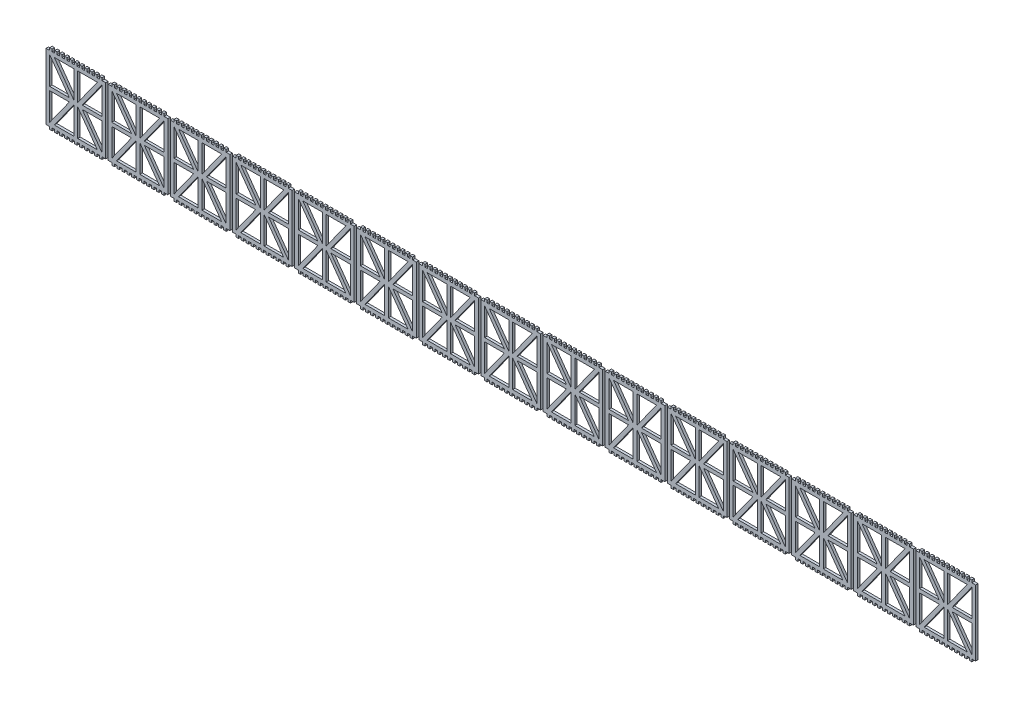
from build123d import *

# Parameters (mm, degrees)
BOSS_EXTRUDE1_DEPTH    = 4
BOSS_EXTRUDE1_2_DEPTH  = 4
BOSS_EXTRUDE1_3_DEPTH  = 4
BOSS_EXTRUDE1_4_DEPTH  = 4
BOSS_EXTRUDE1_5_DEPTH  = 4
BOSS_EXTRUDE1_6_DEPTH  = 4
BOSS_EXTRUDE1_7_DEPTH  = 4
BOSS_EXTRUDE1_8_DEPTH  = 4
BOSS_EXTRUDE1_9_DEPTH  = 4
BOSS_EXTRUDE1_10_DEPTH = 4
BOSS_EXTRUDE1_11_DEPTH = 4
BOSS_EXTRUDE1_12_DEPTH = 4
BOSS_EXTRUDE1_13_DEPTH = 4
BOSS_EXTRUDE1_14_DEPTH = 4
BOSS_EXTRUDE1_15_DEPTH = 4
CUT_EXTRUDE5_DEPTH     = 4


with BuildPart() as part:
    # Sketch1 → Boss-Extrude1 (new body)
    with BuildSketch(Plane.XY):
        Polygon((-42.553329981, 24.0700813), (-36.553329981, 24.0700813), (-36.553329981, 28.0700813), (-32.553329981, 28.0700813), (-32.553329981, 24.0700813), (-28.553329981, 24.0700813), (-28.553329981, 28.0700813), (-24.553329981, 28.0700813), (-24.553329981, 24.0700813), (-20.553329981, 24.0700813), (-20.553329981, 28.0700813), (-16.553329981, 28.0700813), (-16.553329981, 24.0700813), (-12.553329981, 24.0700813), (-12.553329981, 28.0700813), (-8.553329981, 28.0700813), (-8.553329981, 24.0700813), (-4.553329981, 24.0700813), (-4.553329981, 28.0700813), (-0.553329981, 28.0700813), (-0.553329981, 24.0700813), (3.446670019, 24.0700813), (3.446670019, 28.0700813), (7.446670019, 28.0700813), (7.446670019, 24.0700813), (11.446670019, 24.0700813), (11.446670019, 28.0700813), (15.446670019, 28.0700813), (15.446670019, 24.0700813), (19.446670019, 24.0700813), (19.446670019, 28.0700813), (23.446670019, 28.0700813), (23.446670019, 24.0700813), (27.446670019, 24.0700813), (27.446670019, 28.0700813), (31.446670019, 28.0700813), (31.446670019, 24.0700813), (35.446670019, 24.0700813), (35.446670019, 28.0700813), (39.446670019, 28.0700813), (39.446670019, 24.0700813), (43.446670019, 24.0700813), (43.446670019, 28.0700813), (47.446670019, 28.0700813), (47.446670019, 24.0700813), (51.446670019, 24.0700813), (53.446670019, 24.0700813), (53.446670019, -82.0699187), (51.446670019, -82.0699187), (47.446670019, -82.0699187), (47.446670019, -86.0699187), (43.446670019, -86.0699187), (43.446670019, -82.0699187), (39.446670019, -82.0699187), (39.446670019, -86.0699187), (35.446670019, -86.0699187), (35.446670019, -82.0699187), (31.446670019, -82.0699187), (31.446670019, -86.0699187), (27.446670019, -86.0699187), (27.446670019, -82.0699187), (23.446670019, -82.0699187), (23.446670019, -86.0699187), (19.446670019, -86.0699187), (19.446670019, -82.0699187), (15.446670019, -82.0699187), (15.446670019, -86.0699187), (11.446670019, -86.0699187), (11.446670019, -82.0699187), (7.446670019, -82.0699187), (7.446670019, -86.0699187), (3.446670019, -86.0699187), (3.446670019, -82.0699187), (-0.553329981, -82.0699187), (-0.553329981, -86.0699187), (-4.553329981, -86.0699187), (-4.553329981, -82.0699187), (-8.553329981, -82.0699187), (-8.553329981, -86.0699187), (-12.553329981, -86.0699187), (-12.553329981, -82.0699187), (-16.553329981, -82.0699187), (-16.553329981, -86.0699187), (-20.553329981, -86.0699187), (-20.553329981, -82.0699187), (-24.553329981, -82.0699187), (-24.553329981, -86.0699187), (-28.553329981, -86.0699187), (-28.553329981, -82.0699187), (-32.553329981, -82.0699187), (-32.553329981, -86.0699187), (-36.553329981, -86.0699187), (-36.553329981, -82.0699187), (-42.553329981, -82.0699187), align=None)
    extrude(amount=BOSS_EXTRUDE1_DEPTH)


with BuildPart() as body_2:
    # Sketch1 → Boss-Extrude1 2 (new body)
    with BuildSketch(Plane.XY):
        Polygon((57.446670019, 24.0700813), (63.446670019, 24.0700813), (63.446670019, 28.0700813), (67.446670019, 28.0700813), (67.446670019, 24.0700813), (71.446670019, 24.0700813), (71.446670019, 28.0700813), (75.446670019, 28.0700813), (75.446670019, 24.0700813), (79.446670019, 24.0700813), (79.446670019, 28.0700813), (83.446670019, 28.0700813), (83.446670019, 24.0700813), (87.446670019, 24.0700813), (87.446670019, 28.0700813), (91.446670019, 28.0700813), (91.446670019, 24.0700813), (95.446670019, 24.0700813), (95.446670019, 28.0700813), (99.446670019, 28.0700813), (99.446670019, 24.0700813), (103.446670019, 24.0700813), (103.446670019, 28.0700813), (107.446670019, 28.0700813), (107.446670019, 24.0700813), (111.446670019, 24.0700813), (111.446670019, 28.0700813), (115.446670019, 28.0700813), (115.446670019, 24.0700813), (119.446670019, 24.0700813), (119.446670019, 28.0700813), (123.446670019, 28.0700813), (123.446670019, 24.0700813), (127.446670019, 24.0700813), (127.446670019, 28.0700813), (131.446670019, 28.0700813), (131.446670019, 24.0700813), (135.446670019, 24.0700813), (135.446670019, 28.0700813), (139.446670019, 28.0700813), (139.446670019, 24.0700813), (143.446670019, 24.0700813), (143.446670019, 28.0700813), (147.446670019, 28.0700813), (147.446670019, 24.0700813), (151.446670019, 24.0700813), (153.446670019, 24.0700813), (153.446670019, -82.0699187), (151.446670019, -82.0699187), (147.446670019, -82.0699187), (147.446670019, -86.0699187), (143.446670019, -86.0699187), (143.446670019, -82.0699187), (139.446670019, -82.0699187), (139.446670019, -86.0699187), (135.446670019, -86.0699187), (135.446670019, -82.0699187), (131.446670019, -82.0699187), (131.446670019, -86.0699187), (127.446670019, -86.0699187), (127.446670019, -82.0699187), (123.446670019, -82.0699187), (123.446670019, -86.0699187), (119.446670019, -86.0699187), (119.446670019, -82.0699187), (115.446670019, -82.0699187), (115.446670019, -86.0699187), (111.446670019, -86.0699187), (111.446670019, -82.0699187), (107.446670019, -82.0699187), (107.446670019, -86.0699187), (103.446670019, -86.0699187), (103.446670019, -82.0699187), (99.446670019, -82.0699187), (99.446670019, -86.0699187), (95.446670019, -86.0699187), (95.446670019, -82.0699187), (91.446670019, -82.0699187), (91.446670019, -86.0699187), (87.446670019, -86.0699187), (87.446670019, -82.0699187), (83.446670019, -82.0699187), (83.446670019, -86.0699187), (79.446670019, -86.0699187), (79.446670019, -82.0699187), (75.446670019, -82.0699187), (75.446670019, -86.0699187), (71.446670019, -86.0699187), (71.446670019, -82.0699187), (67.446670019, -82.0699187), (67.446670019, -86.0699187), (63.446670019, -86.0699187), (63.446670019, -82.0699187), (57.446670019, -82.0699187), align=None)
    extrude(amount=BOSS_EXTRUDE1_2_DEPTH)


with BuildPart() as body_3:
    # Sketch1 → Boss-Extrude1 3 (new body)
    with BuildSketch(Plane.XY):
        Polygon((157.446670019, 24.0700813), (163.446670019, 24.0700813), (163.446670019, 28.0700813), (167.446670019, 28.0700813), (167.446670019, 24.0700813), (171.446670019, 24.0700813), (171.446670019, 28.0700813), (175.446670019, 28.0700813), (175.446670019, 24.0700813), (179.446670019, 24.0700813), (179.446670019, 28.0700813), (183.446670019, 28.0700813), (183.446670019, 24.0700813), (187.446670019, 24.0700813), (187.446670019, 28.0700813), (191.446670019, 28.0700813), (191.446670019, 24.0700813), (195.446670019, 24.0700813), (195.446670019, 28.0700813), (199.446670019, 28.0700813), (199.446670019, 24.0700813), (203.446670019, 24.0700813), (203.446670019, 28.0700813), (207.446670019, 28.0700813), (207.446670019, 24.0700813), (211.446670019, 24.0700813), (211.446670019, 28.0700813), (215.446670019, 28.0700813), (215.446670019, 24.0700813), (219.446670019, 24.0700813), (219.446670019, 28.0700813), (223.446670019, 28.0700813), (223.446670019, 24.0700813), (227.446670019, 24.0700813), (227.446670019, 28.0700813), (231.446670019, 28.0700813), (231.446670019, 24.0700813), (235.446670019, 24.0700813), (235.446670019, 28.0700813), (239.446670019, 28.0700813), (239.446670019, 24.0700813), (243.446670019, 24.0700813), (243.446670019, 28.0700813), (247.446670019, 28.0700813), (247.446670019, 24.0700813), (251.446670019, 24.0700813), (253.446670019, 24.0700813), (253.446670019, -82.0699187), (251.446670019, -82.0699187), (247.446670019, -82.0699187), (247.446670019, -86.0699187), (243.446670019, -86.0699187), (243.446670019, -82.0699187), (239.446670019, -82.0699187), (239.446670019, -86.0699187), (235.446670019, -86.0699187), (235.446670019, -82.0699187), (231.446670019, -82.0699187), (231.446670019, -86.0699187), (227.446670019, -86.0699187), (227.446670019, -82.0699187), (223.446670019, -82.0699187), (223.446670019, -86.0699187), (219.446670019, -86.0699187), (219.446670019, -82.0699187), (215.446670019, -82.0699187), (215.446670019, -86.0699187), (211.446670019, -86.0699187), (211.446670019, -82.0699187), (207.446670019, -82.0699187), (207.446670019, -86.0699187), (203.446670019, -86.0699187), (203.446670019, -82.0699187), (199.446670019, -82.0699187), (199.446670019, -86.0699187), (195.446670019, -86.0699187), (195.446670019, -82.0699187), (191.446670019, -82.0699187), (191.446670019, -86.0699187), (187.446670019, -86.0699187), (187.446670019, -82.0699187), (183.446670019, -82.0699187), (183.446670019, -86.0699187), (179.446670019, -86.0699187), (179.446670019, -82.0699187), (175.446670019, -82.0699187), (175.446670019, -86.0699187), (171.446670019, -86.0699187), (171.446670019, -82.0699187), (167.446670019, -82.0699187), (167.446670019, -86.0699187), (163.446670019, -86.0699187), (163.446670019, -82.0699187), (157.446670019, -82.0699187), align=None)
    extrude(amount=BOSS_EXTRUDE1_3_DEPTH)


with BuildPart() as body_4:
    # Sketch1 → Boss-Extrude1 4 (new body)
    with BuildSketch(Plane.XY):
        Polygon((257.446670019, 24.0700813), (263.446670019, 24.0700813), (263.446670019, 28.0700813), (267.446670019, 28.0700813), (267.446670019, 24.0700813), (271.446670019, 24.0700813), (271.446670019, 28.0700813), (275.446670019, 28.0700813), (275.446670019, 24.0700813), (279.446670019, 24.0700813), (279.446670019, 28.0700813), (283.446670019, 28.0700813), (283.446670019, 24.0700813), (287.446670019, 24.0700813), (287.446670019, 28.0700813), (291.446670019, 28.0700813), (291.446670019, 24.0700813), (295.446670019, 24.0700813), (295.446670019, 28.0700813), (299.446670019, 28.0700813), (299.446670019, 24.0700813), (303.446670019, 24.0700813), (303.446670019, 28.0700813), (307.446670019, 28.0700813), (307.446670019, 24.0700813), (311.446670019, 24.0700813), (311.446670019, 28.0700813), (315.446670019, 28.0700813), (315.446670019, 24.0700813), (319.446670019, 24.0700813), (319.446670019, 28.0700813), (323.446670019, 28.0700813), (323.446670019, 24.0700813), (327.446670019, 24.0700813), (327.446670019, 28.0700813), (331.446670019, 28.0700813), (331.446670019, 24.0700813), (335.446670019, 24.0700813), (335.446670019, 28.0700813), (339.446670019, 28.0700813), (339.446670019, 24.0700813), (343.446670019, 24.0700813), (343.446670019, 28.0700813), (347.446670019, 28.0700813), (347.446670019, 24.0700813), (351.446670019, 24.0700813), (353.446670019, 24.0700813), (353.446670019, -82.0699187), (351.446670019, -82.0699187), (347.446670019, -82.0699187), (347.446670019, -86.0699187), (343.446670019, -86.0699187), (343.446670019, -82.0699187), (339.446670019, -82.0699187), (339.446670019, -86.0699187), (335.446670019, -86.0699187), (335.446670019, -82.0699187), (331.446670019, -82.0699187), (331.446670019, -86.0699187), (327.446670019, -86.0699187), (327.446670019, -82.0699187), (323.446670019, -82.0699187), (323.446670019, -86.0699187), (319.446670019, -86.0699187), (319.446670019, -82.0699187), (315.446670019, -82.0699187), (315.446670019, -86.0699187), (311.446670019, -86.0699187), (311.446670019, -82.0699187), (307.446670019, -82.0699187), (307.446670019, -86.0699187), (303.446670019, -86.0699187), (303.446670019, -82.0699187), (299.446670019, -82.0699187), (299.446670019, -86.0699187), (295.446670019, -86.0699187), (295.446670019, -82.0699187), (291.446670019, -82.0699187), (291.446670019, -86.0699187), (287.446670019, -86.0699187), (287.446670019, -82.0699187), (283.446670019, -82.0699187), (283.446670019, -86.0699187), (279.446670019, -86.0699187), (279.446670019, -82.0699187), (275.446670019, -82.0699187), (275.446670019, -86.0699187), (271.446670019, -86.0699187), (271.446670019, -82.0699187), (267.446670019, -82.0699187), (267.446670019, -86.0699187), (263.446670019, -86.0699187), (263.446670019, -82.0699187), (257.446670019, -82.0699187), align=None)
    extrude(amount=BOSS_EXTRUDE1_4_DEPTH)


with BuildPart() as body_5:
    # Sketch1 → Boss-Extrude1 5 (new body)
    with BuildSketch(Plane.XY):
        Polygon((357.446670019, 24.0700813), (363.446670019, 24.0700813), (363.446670019, 28.0700813), (367.446670019, 28.0700813), (367.446670019, 24.0700813), (371.446670019, 24.0700813), (371.446670019, 28.0700813), (375.446670019, 28.0700813), (375.446670019, 24.0700813), (379.446670019, 24.0700813), (379.446670019, 28.0700813), (383.446670019, 28.0700813), (383.446670019, 24.0700813), (387.446670019, 24.0700813), (387.446670019, 28.0700813), (391.446670019, 28.0700813), (391.446670019, 24.0700813), (395.446670019, 24.0700813), (395.446670019, 28.0700813), (399.446670019, 28.0700813), (399.446670019, 24.0700813), (403.446670019, 24.0700813), (403.446670019, 28.0700813), (407.446670019, 28.0700813), (407.446670019, 24.0700813), (411.446670019, 24.0700813), (411.446670019, 28.0700813), (415.446670019, 28.0700813), (415.446670019, 24.0700813), (419.446670019, 24.0700813), (419.446670019, 28.0700813), (423.446670019, 28.0700813), (423.446670019, 24.0700813), (427.446670019, 24.0700813), (427.446670019, 28.0700813), (431.446670019, 28.0700813), (431.446670019, 24.0700813), (435.446670019, 24.0700813), (435.446670019, 28.0700813), (439.446670019, 28.0700813), (439.446670019, 24.0700813), (443.446670019, 24.0700813), (443.446670019, 28.0700813), (447.446670019, 28.0700813), (447.446670019, 24.0700813), (451.446670019, 24.0700813), (453.446670019, 24.0700813), (453.446670019, -82.0699187), (451.446670019, -82.0699187), (447.446670019, -82.0699187), (447.446670019, -86.0699187), (443.446670019, -86.0699187), (443.446670019, -82.0699187), (439.446670019, -82.0699187), (439.446670019, -86.0699187), (435.446670019, -86.0699187), (435.446670019, -82.0699187), (431.446670019, -82.0699187), (431.446670019, -86.0699187), (427.446670019, -86.0699187), (427.446670019, -82.0699187), (423.446670019, -82.0699187), (423.446670019, -86.0699187), (419.446670019, -86.0699187), (419.446670019, -82.0699187), (415.446670019, -82.0699187), (415.446670019, -86.0699187), (411.446670019, -86.0699187), (411.446670019, -82.0699187), (407.446670019, -82.0699187), (407.446670019, -86.0699187), (403.446670019, -86.0699187), (403.446670019, -82.0699187), (399.446670019, -82.0699187), (399.446670019, -86.0699187), (395.446670019, -86.0699187), (395.446670019, -82.0699187), (391.446670019, -82.0699187), (391.446670019, -86.0699187), (387.446670019, -86.0699187), (387.446670019, -82.0699187), (383.446670019, -82.0699187), (383.446670019, -86.0699187), (379.446670019, -86.0699187), (379.446670019, -82.0699187), (375.446670019, -82.0699187), (375.446670019, -86.0699187), (371.446670019, -86.0699187), (371.446670019, -82.0699187), (367.446670019, -82.0699187), (367.446670019, -86.0699187), (363.446670019, -86.0699187), (363.446670019, -82.0699187), (357.446670019, -82.0699187), align=None)
    extrude(amount=BOSS_EXTRUDE1_5_DEPTH)


with BuildPart() as body_6:
    # Sketch1 → Boss-Extrude1 6 (new body)
    with BuildSketch(Plane.XY):
        Polygon((457.446670019, 24.0700813), (463.446670019, 24.0700813), (463.446670019, 28.0700813), (467.446670019, 28.0700813), (467.446670019, 24.0700813), (471.446670019, 24.0700813), (471.446670019, 28.0700813), (475.446670019, 28.0700813), (475.446670019, 24.0700813), (479.446670019, 24.0700813), (479.446670019, 28.0700813), (483.446670019, 28.0700813), (483.446670019, 24.0700813), (487.446670019, 24.0700813), (487.446670019, 28.0700813), (491.446670019, 28.0700813), (491.446670019, 24.0700813), (495.446670019, 24.0700813), (495.446670019, 28.0700813), (499.446670019, 28.0700813), (499.446670019, 24.0700813), (503.446670019, 24.0700813), (503.446670019, 28.0700813), (507.446670019, 28.0700813), (507.446670019, 24.0700813), (511.446670019, 24.0700813), (511.446670019, 28.0700813), (515.446670019, 28.0700813), (515.446670019, 24.0700813), (519.446670019, 24.0700813), (519.446670019, 28.0700813), (523.446670019, 28.0700813), (523.446670019, 24.0700813), (527.446670019, 24.0700813), (527.446670019, 28.0700813), (531.446670019, 28.0700813), (531.446670019, 24.0700813), (535.446670019, 24.0700813), (535.446670019, 28.0700813), (539.446670019, 28.0700813), (539.446670019, 24.0700813), (543.446670019, 24.0700813), (543.446670019, 28.0700813), (547.446670019, 28.0700813), (547.446670019, 24.0700813), (551.446670019, 24.0700813), (553.446670019, 24.0700813), (553.446670019, -82.0699187), (551.446670019, -82.0699187), (547.446670019, -82.0699187), (547.446670019, -86.0699187), (543.446670019, -86.0699187), (543.446670019, -82.0699187), (539.446670019, -82.0699187), (539.446670019, -86.0699187), (535.446670019, -86.0699187), (535.446670019, -82.0699187), (531.446670019, -82.0699187), (531.446670019, -86.0699187), (527.446670019, -86.0699187), (527.446670019, -82.0699187), (523.446670019, -82.0699187), (523.446670019, -86.0699187), (519.446670019, -86.0699187), (519.446670019, -82.0699187), (515.446670019, -82.0699187), (515.446670019, -86.0699187), (511.446670019, -86.0699187), (511.446670019, -82.0699187), (507.446670019, -82.0699187), (507.446670019, -86.0699187), (503.446670019, -86.0699187), (503.446670019, -82.0699187), (499.446670019, -82.0699187), (499.446670019, -86.0699187), (495.446670019, -86.0699187), (495.446670019, -82.0699187), (491.446670019, -82.0699187), (491.446670019, -86.0699187), (487.446670019, -86.0699187), (487.446670019, -82.0699187), (483.446670019, -82.0699187), (483.446670019, -86.0699187), (479.446670019, -86.0699187), (479.446670019, -82.0699187), (475.446670019, -82.0699187), (475.446670019, -86.0699187), (471.446670019, -86.0699187), (471.446670019, -82.0699187), (467.446670019, -82.0699187), (467.446670019, -86.0699187), (463.446670019, -86.0699187), (463.446670019, -82.0699187), (457.446670019, -82.0699187), align=None)
    extrude(amount=BOSS_EXTRUDE1_6_DEPTH)


with BuildPart() as body_7:
    # Sketch1 → Boss-Extrude1 7 (new body)
    with BuildSketch(Plane.XY):
        Polygon((557.446670019, 24.0700813), (563.446670019, 24.0700813), (563.446670019, 28.0700813), (567.446670019, 28.0700813), (567.446670019, 24.0700813), (571.446670019, 24.0700813), (571.446670019, 28.0700813), (575.446670019, 28.0700813), (575.446670019, 24.0700813), (579.446670019, 24.0700813), (579.446670019, 28.0700813), (583.446670019, 28.0700813), (583.446670019, 24.0700813), (587.446670019, 24.0700813), (587.446670019, 28.0700813), (591.446670019, 28.0700813), (591.446670019, 24.0700813), (595.446670019, 24.0700813), (595.446670019, 28.0700813), (599.446670019, 28.0700813), (599.446670019, 24.0700813), (603.446670019, 24.0700813), (603.446670019, 28.0700813), (607.446670019, 28.0700813), (607.446670019, 24.0700813), (611.446670019, 24.0700813), (611.446670019, 28.0700813), (615.446670019, 28.0700813), (615.446670019, 24.0700813), (619.446670019, 24.0700813), (619.446670019, 28.0700813), (623.446670019, 28.0700813), (623.446670019, 24.0700813), (627.446670019, 24.0700813), (627.446670019, 28.0700813), (631.446670019, 28.0700813), (631.446670019, 24.0700813), (635.446670019, 24.0700813), (635.446670019, 28.0700813), (639.446670019, 28.0700813), (639.446670019, 24.0700813), (643.446670019, 24.0700813), (643.446670019, 28.0700813), (647.446670019, 28.0700813), (647.446670019, 24.0700813), (651.446670019, 24.0700813), (653.446670019, 24.0700813), (653.446670019, -82.0699187), (651.446670019, -82.0699187), (647.446670019, -82.0699187), (647.446670019, -86.0699187), (643.446670019, -86.0699187), (643.446670019, -82.0699187), (639.446670019, -82.0699187), (639.446670019, -86.0699187), (635.446670019, -86.0699187), (635.446670019, -82.0699187), (631.446670019, -82.0699187), (631.446670019, -86.0699187), (627.446670019, -86.0699187), (627.446670019, -82.0699187), (623.446670019, -82.0699187), (623.446670019, -86.0699187), (619.446670019, -86.0699187), (619.446670019, -82.0699187), (615.446670019, -82.0699187), (615.446670019, -86.0699187), (611.446670019, -86.0699187), (611.446670019, -82.0699187), (607.446670019, -82.0699187), (607.446670019, -86.0699187), (603.446670019, -86.0699187), (603.446670019, -82.0699187), (599.446670019, -82.0699187), (599.446670019, -86.0699187), (595.446670019, -86.0699187), (595.446670019, -82.0699187), (591.446670019, -82.0699187), (591.446670019, -86.0699187), (587.446670019, -86.0699187), (587.446670019, -82.0699187), (583.446670019, -82.0699187), (583.446670019, -86.0699187), (579.446670019, -86.0699187), (579.446670019, -82.0699187), (575.446670019, -82.0699187), (575.446670019, -86.0699187), (571.446670019, -86.0699187), (571.446670019, -82.0699187), (567.446670019, -82.0699187), (567.446670019, -86.0699187), (563.446670019, -86.0699187), (563.446670019, -82.0699187), (557.446670019, -82.0699187), align=None)
    extrude(amount=BOSS_EXTRUDE1_7_DEPTH)


with BuildPart() as body_8:
    # Sketch1 → Boss-Extrude1 8 (new body)
    with BuildSketch(Plane.XY):
        Polygon((657.446670019, 24.0700813), (663.446670019, 24.0700813), (663.446670019, 28.0700813), (667.446670019, 28.0700813), (667.446670019, 24.0700813), (671.446670019, 24.0700813), (671.446670019, 28.0700813), (675.446670019, 28.0700813), (675.446670019, 24.0700813), (679.446670019, 24.0700813), (679.446670019, 28.0700813), (683.446670019, 28.0700813), (683.446670019, 24.0700813), (687.446670019, 24.0700813), (687.446670019, 28.0700813), (691.446670019, 28.0700813), (691.446670019, 24.0700813), (695.446670019, 24.0700813), (695.446670019, 28.0700813), (699.446670019, 28.0700813), (699.446670019, 24.0700813), (703.446670019, 24.0700813), (703.446670019, 28.0700813), (707.446670019, 28.0700813), (707.446670019, 24.0700813), (711.446670019, 24.0700813), (711.446670019, 28.0700813), (715.446670019, 28.0700813), (715.446670019, 24.0700813), (719.446670019, 24.0700813), (719.446670019, 28.0700813), (723.446670019, 28.0700813), (723.446670019, 24.0700813), (727.446670019, 24.0700813), (727.446670019, 28.0700813), (731.446670019, 28.0700813), (731.446670019, 24.0700813), (735.446670019, 24.0700813), (735.446670019, 28.0700813), (739.446670019, 28.0700813), (739.446670019, 24.0700813), (743.446670019, 24.0700813), (743.446670019, 28.0700813), (747.446670019, 28.0700813), (747.446670019, 24.0700813), (751.446670019, 24.0700813), (753.446670019, 24.0700813), (753.446670019, -82.0699187), (751.446670019, -82.0699187), (747.446670019, -82.0699187), (747.446670019, -86.0699187), (743.446670019, -86.0699187), (743.446670019, -82.0699187), (739.446670019, -82.0699187), (739.446670019, -86.0699187), (735.446670019, -86.0699187), (735.446670019, -82.0699187), (731.446670019, -82.0699187), (731.446670019, -86.0699187), (727.446670019, -86.0699187), (727.446670019, -82.0699187), (723.446670019, -82.0699187), (723.446670019, -86.0699187), (719.446670019, -86.0699187), (719.446670019, -82.0699187), (715.446670019, -82.0699187), (715.446670019, -86.0699187), (711.446670019, -86.0699187), (711.446670019, -82.0699187), (707.446670019, -82.0699187), (707.446670019, -86.0699187), (703.446670019, -86.0699187), (703.446670019, -82.0699187), (699.446670019, -82.0699187), (699.446670019, -86.0699187), (695.446670019, -86.0699187), (695.446670019, -82.0699187), (691.446670019, -82.0699187), (691.446670019, -86.0699187), (687.446670019, -86.0699187), (687.446670019, -82.0699187), (683.446670019, -82.0699187), (683.446670019, -86.0699187), (679.446670019, -86.0699187), (679.446670019, -82.0699187), (675.446670019, -82.0699187), (675.446670019, -86.0699187), (671.446670019, -86.0699187), (671.446670019, -82.0699187), (667.446670019, -82.0699187), (667.446670019, -86.0699187), (663.446670019, -86.0699187), (663.446670019, -82.0699187), (657.446670019, -82.0699187), align=None)
    extrude(amount=BOSS_EXTRUDE1_8_DEPTH)


with BuildPart() as body_9:
    # Sketch1 → Boss-Extrude1 9 (new body)
    with BuildSketch(Plane.XY):
        Polygon((757.446670019, 24.0700813), (763.446670019, 24.0700813), (763.446670019, 28.0700813), (767.446670019, 28.0700813), (767.446670019, 24.0700813), (771.446670019, 24.0700813), (771.446670019, 28.0700813), (775.446670019, 28.0700813), (775.446670019, 24.0700813), (779.446670019, 24.0700813), (779.446670019, 28.0700813), (783.446670019, 28.0700813), (783.446670019, 24.0700813), (787.446670019, 24.0700813), (787.446670019, 28.0700813), (791.446670019, 28.0700813), (791.446670019, 24.0700813), (795.446670019, 24.0700813), (795.446670019, 28.0700813), (799.446670019, 28.0700813), (799.446670019, 24.0700813), (803.446670019, 24.0700813), (803.446670019, 28.0700813), (807.446670019, 28.0700813), (807.446670019, 24.0700813), (811.446670019, 24.0700813), (811.446670019, 28.0700813), (815.446670019, 28.0700813), (815.446670019, 24.0700813), (819.446670019, 24.0700813), (819.446670019, 28.0700813), (823.446670019, 28.0700813), (823.446670019, 24.0700813), (827.446670019, 24.0700813), (827.446670019, 28.0700813), (831.446670019, 28.0700813), (831.446670019, 24.0700813), (835.446670019, 24.0700813), (835.446670019, 28.0700813), (839.446670019, 28.0700813), (839.446670019, 24.0700813), (843.446670019, 24.0700813), (843.446670019, 28.0700813), (847.446670019, 28.0700813), (847.446670019, 24.0700813), (851.446670019, 24.0700813), (853.446670019, 24.0700813), (853.446670019, -82.0699187), (851.446670019, -82.0699187), (847.446670019, -82.0699187), (847.446670019, -86.0699187), (843.446670019, -86.0699187), (843.446670019, -82.0699187), (839.446670019, -82.0699187), (839.446670019, -86.0699187), (835.446670019, -86.0699187), (835.446670019, -82.0699187), (831.446670019, -82.0699187), (831.446670019, -86.0699187), (827.446670019, -86.0699187), (827.446670019, -82.0699187), (823.446670019, -82.0699187), (823.446670019, -86.0699187), (819.446670019, -86.0699187), (819.446670019, -82.0699187), (815.446670019, -82.0699187), (815.446670019, -86.0699187), (811.446670019, -86.0699187), (811.446670019, -82.0699187), (807.446670019, -82.0699187), (807.446670019, -86.0699187), (803.446670019, -86.0699187), (803.446670019, -82.0699187), (799.446670019, -82.0699187), (799.446670019, -86.0699187), (795.446670019, -86.0699187), (795.446670019, -82.0699187), (791.446670019, -82.0699187), (791.446670019, -86.0699187), (787.446670019, -86.0699187), (787.446670019, -82.0699187), (783.446670019, -82.0699187), (783.446670019, -86.0699187), (779.446670019, -86.0699187), (779.446670019, -82.0699187), (775.446670019, -82.0699187), (775.446670019, -86.0699187), (771.446670019, -86.0699187), (771.446670019, -82.0699187), (767.446670019, -82.0699187), (767.446670019, -86.0699187), (763.446670019, -86.0699187), (763.446670019, -82.0699187), (757.446670019, -82.0699187), align=None)
    extrude(amount=BOSS_EXTRUDE1_9_DEPTH)


with BuildPart() as body_10:
    # Sketch1 → Boss-Extrude1 10 (new body)
    with BuildSketch(Plane.XY):
        Polygon((857.446670019, 24.0700813), (863.446670019, 24.0700813), (863.446670019, 28.0700813), (867.446670019, 28.0700813), (867.446670019, 24.0700813), (871.446670019, 24.0700813), (871.446670019, 28.0700813), (875.446670019, 28.0700813), (875.446670019, 24.0700813), (879.446670019, 24.0700813), (879.446670019, 28.0700813), (883.446670019, 28.0700813), (883.446670019, 24.0700813), (887.446670019, 24.0700813), (887.446670019, 28.0700813), (891.446670019, 28.0700813), (891.446670019, 24.0700813), (895.446670019, 24.0700813), (895.446670019, 28.0700813), (899.446670019, 28.0700813), (899.446670019, 24.0700813), (903.446670019, 24.0700813), (903.446670019, 28.0700813), (907.446670019, 28.0700813), (907.446670019, 24.0700813), (911.446670019, 24.0700813), (911.446670019, 28.0700813), (915.446670019, 28.0700813), (915.446670019, 24.0700813), (919.446670019, 24.0700813), (919.446670019, 28.0700813), (923.446670019, 28.0700813), (923.446670019, 24.0700813), (927.446670019, 24.0700813), (927.446670019, 28.0700813), (931.446670019, 28.0700813), (931.446670019, 24.0700813), (935.446670019, 24.0700813), (935.446670019, 28.0700813), (939.446670019, 28.0700813), (939.446670019, 24.0700813), (943.446670019, 24.0700813), (943.446670019, 28.0700813), (947.446670019, 28.0700813), (947.446670019, 24.0700813), (951.446670019, 24.0700813), (953.446670019, 24.0700813), (953.446670019, -82.0699187), (951.446670019, -82.0699187), (947.446670019, -82.0699187), (947.446670019, -86.0699187), (943.446670019, -86.0699187), (943.446670019, -82.0699187), (939.446670019, -82.0699187), (939.446670019, -86.0699187), (935.446670019, -86.0699187), (935.446670019, -82.0699187), (931.446670019, -82.0699187), (931.446670019, -86.0699187), (927.446670019, -86.0699187), (927.446670019, -82.0699187), (923.446670019, -82.0699187), (923.446670019, -86.0699187), (919.446670019, -86.0699187), (919.446670019, -82.0699187), (915.446670019, -82.0699187), (915.446670019, -86.0699187), (911.446670019, -86.0699187), (911.446670019, -82.0699187), (907.446670019, -82.0699187), (907.446670019, -86.0699187), (903.446670019, -86.0699187), (903.446670019, -82.0699187), (899.446670019, -82.0699187), (899.446670019, -86.0699187), (895.446670019, -86.0699187), (895.446670019, -82.0699187), (891.446670019, -82.0699187), (891.446670019, -86.0699187), (887.446670019, -86.0699187), (887.446670019, -82.0699187), (883.446670019, -82.0699187), (883.446670019, -86.0699187), (879.446670019, -86.0699187), (879.446670019, -82.0699187), (875.446670019, -82.0699187), (875.446670019, -86.0699187), (871.446670019, -86.0699187), (871.446670019, -82.0699187), (867.446670019, -82.0699187), (867.446670019, -86.0699187), (863.446670019, -86.0699187), (863.446670019, -82.0699187), (857.446670019, -82.0699187), align=None)
    extrude(amount=BOSS_EXTRUDE1_10_DEPTH)


with BuildPart() as body_11:
    # Sketch1 → Boss-Extrude1 11 (new body)
    with BuildSketch(Plane.XY):
        Polygon((957.446670019, 24.0700813), (963.446670019, 24.0700813), (963.446670019, 28.0700813), (967.446670019, 28.0700813), (967.446670019, 24.0700813), (971.446670019, 24.0700813), (971.446670019, 28.0700813), (975.446670019, 28.0700813), (975.446670019, 24.0700813), (979.446670019, 24.0700813), (979.446670019, 28.0700813), (983.446670019, 28.0700813), (983.446670019, 24.0700813), (987.446670019, 24.0700813), (987.446670019, 28.0700813), (991.446670019, 28.0700813), (991.446670019, 24.0700813), (995.446670019, 24.0700813), (995.446670019, 28.0700813), (999.446670019, 28.0700813), (999.446670019, 24.0700813), (1003.446670019, 24.0700813), (1003.446670019, 28.0700813), (1007.446670019, 28.0700813), (1007.446670019, 24.0700813), (1011.446670019, 24.0700813), (1011.446670019, 28.0700813), (1015.446670019, 28.0700813), (1015.446670019, 24.0700813), (1019.446670019, 24.0700813), (1019.446670019, 28.0700813), (1023.446670019, 28.0700813), (1023.446670019, 24.0700813), (1027.446670019, 24.0700813), (1027.446670019, 28.0700813), (1031.446670019, 28.0700813), (1031.446670019, 24.0700813), (1035.446670019, 24.0700813), (1035.446670019, 28.0700813), (1039.446670019, 28.0700813), (1039.446670019, 24.0700813), (1043.446670019, 24.0700813), (1043.446670019, 28.0700813), (1047.446670019, 28.0700813), (1047.446670019, 24.0700813), (1051.446670019, 24.0700813), (1053.446670019, 24.0700813), (1053.446670019, -82.0699187), (1051.446670019, -82.0699187), (1047.446670019, -82.0699187), (1047.446670019, -86.0699187), (1043.446670019, -86.0699187), (1043.446670019, -82.0699187), (1039.446670019, -82.0699187), (1039.446670019, -86.0699187), (1035.446670019, -86.0699187), (1035.446670019, -82.0699187), (1031.446670019, -82.0699187), (1031.446670019, -86.0699187), (1027.446670019, -86.0699187), (1027.446670019, -82.0699187), (1023.446670019, -82.0699187), (1023.446670019, -86.0699187), (1019.446670019, -86.0699187), (1019.446670019, -82.0699187), (1015.446670019, -82.0699187), (1015.446670019, -86.0699187), (1011.446670019, -86.0699187), (1011.446670019, -82.0699187), (1007.446670019, -82.0699187), (1007.446670019, -86.0699187), (1003.446670019, -86.0699187), (1003.446670019, -82.0699187), (999.446670019, -82.0699187), (999.446670019, -86.0699187), (995.446670019, -86.0699187), (995.446670019, -82.0699187), (991.446670019, -82.0699187), (991.446670019, -86.0699187), (987.446670019, -86.0699187), (987.446670019, -82.0699187), (983.446670019, -82.0699187), (983.446670019, -86.0699187), (979.446670019, -86.0699187), (979.446670019, -82.0699187), (975.446670019, -82.0699187), (975.446670019, -86.0699187), (971.446670019, -86.0699187), (971.446670019, -82.0699187), (967.446670019, -82.0699187), (967.446670019, -86.0699187), (963.446670019, -86.0699187), (963.446670019, -82.0699187), (957.446670019, -82.0699187), align=None)
    extrude(amount=BOSS_EXTRUDE1_11_DEPTH)


with BuildPart() as body_12:
    # Sketch1 → Boss-Extrude1 12 (new body)
    with BuildSketch(Plane.XY):
        Polygon((1057.446670019, 24.0700813), (1063.446670019, 24.0700813), (1063.446670019, 28.0700813), (1067.446670019, 28.0700813), (1067.446670019, 24.0700813), (1071.446670019, 24.0700813), (1071.446670019, 28.0700813), (1075.446670019, 28.0700813), (1075.446670019, 24.0700813), (1079.446670019, 24.0700813), (1079.446670019, 28.0700813), (1083.446670019, 28.0700813), (1083.446670019, 24.0700813), (1087.446670019, 24.0700813), (1087.446670019, 28.0700813), (1091.446670019, 28.0700813), (1091.446670019, 24.0700813), (1095.446670019, 24.0700813), (1095.446670019, 28.0700813), (1099.446670019, 28.0700813), (1099.446670019, 24.0700813), (1103.446670019, 24.0700813), (1103.446670019, 28.0700813), (1107.446670019, 28.0700813), (1107.446670019, 24.0700813), (1111.446670019, 24.0700813), (1111.446670019, 28.0700813), (1115.446670019, 28.0700813), (1115.446670019, 24.0700813), (1119.446670019, 24.0700813), (1119.446670019, 28.0700813), (1123.446670019, 28.0700813), (1123.446670019, 24.0700813), (1127.446670019, 24.0700813), (1127.446670019, 28.0700813), (1131.446670019, 28.0700813), (1131.446670019, 24.0700813), (1135.446670019, 24.0700813), (1135.446670019, 28.0700813), (1139.446670019, 28.0700813), (1139.446670019, 24.0700813), (1143.446670019, 24.0700813), (1143.446670019, 28.0700813), (1147.446670019, 28.0700813), (1147.446670019, 24.0700813), (1151.446670019, 24.0700813), (1153.446670019, 24.0700813), (1153.446670019, -82.0699187), (1151.446670019, -82.0699187), (1147.446670019, -82.0699187), (1147.446670019, -86.0699187), (1143.446670019, -86.0699187), (1143.446670019, -82.0699187), (1139.446670019, -82.0699187), (1139.446670019, -86.0699187), (1135.446670019, -86.0699187), (1135.446670019, -82.0699187), (1131.446670019, -82.0699187), (1131.446670019, -86.0699187), (1127.446670019, -86.0699187), (1127.446670019, -82.0699187), (1123.446670019, -82.0699187), (1123.446670019, -86.0699187), (1119.446670019, -86.0699187), (1119.446670019, -82.0699187), (1115.446670019, -82.0699187), (1115.446670019, -86.0699187), (1111.446670019, -86.0699187), (1111.446670019, -82.0699187), (1107.446670019, -82.0699187), (1107.446670019, -86.0699187), (1103.446670019, -86.0699187), (1103.446670019, -82.0699187), (1099.446670019, -82.0699187), (1099.446670019, -86.0699187), (1095.446670019, -86.0699187), (1095.446670019, -82.0699187), (1091.446670019, -82.0699187), (1091.446670019, -86.0699187), (1087.446670019, -86.0699187), (1087.446670019, -82.0699187), (1083.446670019, -82.0699187), (1083.446670019, -86.0699187), (1079.446670019, -86.0699187), (1079.446670019, -82.0699187), (1075.446670019, -82.0699187), (1075.446670019, -86.0699187), (1071.446670019, -86.0699187), (1071.446670019, -82.0699187), (1067.446670019, -82.0699187), (1067.446670019, -86.0699187), (1063.446670019, -86.0699187), (1063.446670019, -82.0699187), (1057.446670019, -82.0699187), align=None)
    extrude(amount=BOSS_EXTRUDE1_12_DEPTH)


with BuildPart() as body_13:
    # Sketch1 → Boss-Extrude1 13 (new body)
    with BuildSketch(Plane.XY):
        Polygon((1157.446670019, 24.0700813), (1163.446670019, 24.0700813), (1163.446670019, 28.0700813), (1167.446670019, 28.0700813), (1167.446670019, 24.0700813), (1171.446670019, 24.0700813), (1171.446670019, 28.0700813), (1175.446670019, 28.0700813), (1175.446670019, 24.0700813), (1179.446670019, 24.0700813), (1179.446670019, 28.0700813), (1183.446670019, 28.0700813), (1183.446670019, 24.0700813), (1187.446670019, 24.0700813), (1187.446670019, 28.0700813), (1191.446670019, 28.0700813), (1191.446670019, 24.0700813), (1195.446670019, 24.0700813), (1195.446670019, 28.0700813), (1199.446670019, 28.0700813), (1199.446670019, 24.0700813), (1203.446670019, 24.0700813), (1203.446670019, 28.0700813), (1207.446670019, 28.0700813), (1207.446670019, 24.0700813), (1211.446670019, 24.0700813), (1211.446670019, 28.0700813), (1215.446670019, 28.0700813), (1215.446670019, 24.0700813), (1219.446670019, 24.0700813), (1219.446670019, 28.0700813), (1223.446670019, 28.0700813), (1223.446670019, 24.0700813), (1227.446670019, 24.0700813), (1227.446670019, 28.0700813), (1231.446670019, 28.0700813), (1231.446670019, 24.0700813), (1235.446670019, 24.0700813), (1235.446670019, 28.0700813), (1239.446670019, 28.0700813), (1239.446670019, 24.0700813), (1243.446670019, 24.0700813), (1243.446670019, 28.0700813), (1247.446670019, 28.0700813), (1247.446670019, 24.0700813), (1251.446670019, 24.0700813), (1253.446670019, 24.0700813), (1253.446670019, -82.0699187), (1251.446670019, -82.0699187), (1247.446670019, -82.0699187), (1247.446670019, -86.0699187), (1243.446670019, -86.0699187), (1243.446670019, -82.0699187), (1239.446670019, -82.0699187), (1239.446670019, -86.0699187), (1235.446670019, -86.0699187), (1235.446670019, -82.0699187), (1231.446670019, -82.0699187), (1231.446670019, -86.0699187), (1227.446670019, -86.0699187), (1227.446670019, -82.0699187), (1223.446670019, -82.0699187), (1223.446670019, -86.0699187), (1219.446670019, -86.0699187), (1219.446670019, -82.0699187), (1215.446670019, -82.0699187), (1215.446670019, -86.0699187), (1211.446670019, -86.0699187), (1211.446670019, -82.0699187), (1207.446670019, -82.0699187), (1207.446670019, -86.0699187), (1203.446670019, -86.0699187), (1203.446670019, -82.0699187), (1199.446670019, -82.0699187), (1199.446670019, -86.0699187), (1195.446670019, -86.0699187), (1195.446670019, -82.0699187), (1191.446670019, -82.0699187), (1191.446670019, -86.0699187), (1187.446670019, -86.0699187), (1187.446670019, -82.0699187), (1183.446670019, -82.0699187), (1183.446670019, -86.0699187), (1179.446670019, -86.0699187), (1179.446670019, -82.0699187), (1175.446670019, -82.0699187), (1175.446670019, -86.0699187), (1171.446670019, -86.0699187), (1171.446670019, -82.0699187), (1167.446670019, -82.0699187), (1167.446670019, -86.0699187), (1163.446670019, -86.0699187), (1163.446670019, -82.0699187), (1157.446670019, -82.0699187), align=None)
    extrude(amount=BOSS_EXTRUDE1_13_DEPTH)


with BuildPart() as body_14:
    # Sketch1 → Boss-Extrude1 14 (new body)
    with BuildSketch(Plane.XY):
        Polygon((1257.446670019, 24.0700813), (1263.446670019, 24.0700813), (1263.446670019, 28.0700813), (1267.446670019, 28.0700813), (1267.446670019, 24.0700813), (1271.446670019, 24.0700813), (1271.446670019, 28.0700813), (1275.446670019, 28.0700813), (1275.446670019, 24.0700813), (1279.446670019, 24.0700813), (1279.446670019, 28.0700813), (1283.446670019, 28.0700813), (1283.446670019, 24.0700813), (1287.446670019, 24.0700813), (1287.446670019, 28.0700813), (1291.446670019, 28.0700813), (1291.446670019, 24.0700813), (1295.446670019, 24.0700813), (1295.446670019, 28.0700813), (1299.446670019, 28.0700813), (1299.446670019, 24.0700813), (1303.446670019, 24.0700813), (1303.446670019, 28.0700813), (1307.446670019, 28.0700813), (1307.446670019, 24.0700813), (1311.446670019, 24.0700813), (1311.446670019, 28.0700813), (1315.446670019, 28.0700813), (1315.446670019, 24.0700813), (1319.446670019, 24.0700813), (1319.446670019, 28.0700813), (1323.446670019, 28.0700813), (1323.446670019, 24.0700813), (1327.446670019, 24.0700813), (1327.446670019, 28.0700813), (1331.446670019, 28.0700813), (1331.446670019, 24.0700813), (1335.446670019, 24.0700813), (1335.446670019, 28.0700813), (1339.446670019, 28.0700813), (1339.446670019, 24.0700813), (1343.446670019, 24.0700813), (1343.446670019, 28.0700813), (1347.446670019, 28.0700813), (1347.446670019, 24.0700813), (1351.446670019, 24.0700813), (1353.446670019, 24.0700813), (1353.446670019, -82.0699187), (1351.446670019, -82.0699187), (1347.446670019, -82.0699187), (1347.446670019, -86.0699187), (1343.446670019, -86.0699187), (1343.446670019, -82.0699187), (1339.446670019, -82.0699187), (1339.446670019, -86.0699187), (1335.446670019, -86.0699187), (1335.446670019, -82.0699187), (1331.446670019, -82.0699187), (1331.446670019, -86.0699187), (1327.446670019, -86.0699187), (1327.446670019, -82.0699187), (1323.446670019, -82.0699187), (1323.446670019, -86.0699187), (1319.446670019, -86.0699187), (1319.446670019, -82.0699187), (1315.446670019, -82.0699187), (1315.446670019, -86.0699187), (1311.446670019, -86.0699187), (1311.446670019, -82.0699187), (1307.446670019, -82.0699187), (1307.446670019, -86.0699187), (1303.446670019, -86.0699187), (1303.446670019, -82.0699187), (1299.446670019, -82.0699187), (1299.446670019, -86.0699187), (1295.446670019, -86.0699187), (1295.446670019, -82.0699187), (1291.446670019, -82.0699187), (1291.446670019, -86.0699187), (1287.446670019, -86.0699187), (1287.446670019, -82.0699187), (1283.446670019, -82.0699187), (1283.446670019, -86.0699187), (1279.446670019, -86.0699187), (1279.446670019, -82.0699187), (1275.446670019, -82.0699187), (1275.446670019, -86.0699187), (1271.446670019, -86.0699187), (1271.446670019, -82.0699187), (1267.446670019, -82.0699187), (1267.446670019, -86.0699187), (1263.446670019, -86.0699187), (1263.446670019, -82.0699187), (1257.446670019, -82.0699187), align=None)
    extrude(amount=BOSS_EXTRUDE1_14_DEPTH)


with BuildPart() as body_15:
    # Sketch1 → Boss-Extrude1 15 (new body)
    with BuildSketch(Plane.XY):
        Polygon((1357.446670019, 24.0700813), (1363.446670019, 24.0700813), (1363.446670019, 28.0700813), (1367.446670019, 28.0700813), (1367.446670019, 24.0700813), (1371.446670019, 24.0700813), (1371.446670019, 28.0700813), (1375.446670019, 28.0700813), (1375.446670019, 24.0700813), (1379.446670019, 24.0700813), (1379.446670019, 28.0700813), (1383.446670019, 28.0700813), (1383.446670019, 24.0700813), (1387.446670019, 24.0700813), (1387.446670019, 28.0700813), (1391.446670019, 28.0700813), (1391.446670019, 24.0700813), (1395.446670019, 24.0700813), (1395.446670019, 28.0700813), (1399.446670019, 28.0700813), (1399.446670019, 24.0700813), (1403.446670019, 24.0700813), (1403.446670019, 28.0700813), (1407.446670019, 28.0700813), (1407.446670019, 24.0700813), (1411.446670019, 24.0700813), (1411.446670019, 28.0700813), (1415.446670019, 28.0700813), (1415.446670019, 24.0700813), (1419.446670019, 24.0700813), (1419.446670019, 28.0700813), (1423.446670019, 28.0700813), (1423.446670019, 24.0700813), (1427.446670019, 24.0700813), (1427.446670019, 28.0700813), (1431.446670019, 28.0700813), (1431.446670019, 24.0700813), (1435.446670019, 24.0700813), (1435.446670019, 28.0700813), (1439.446670019, 28.0700813), (1439.446670019, 24.0700813), (1443.446670019, 24.0700813), (1443.446670019, 28.0700813), (1447.446670019, 28.0700813), (1447.446670019, 24.0700813), (1451.446670019, 24.0700813), (1453.446670019, 24.0700813), (1453.446670019, -82.0699187), (1451.446670019, -82.0699187), (1447.446670019, -82.0699187), (1447.446670019, -86.0699187), (1443.446670019, -86.0699187), (1443.446670019, -82.0699187), (1439.446670019, -82.0699187), (1439.446670019, -86.0699187), (1435.446670019, -86.0699187), (1435.446670019, -82.0699187), (1431.446670019, -82.0699187), (1431.446670019, -86.0699187), (1427.446670019, -86.0699187), (1427.446670019, -82.0699187), (1423.446670019, -82.0699187), (1423.446670019, -86.0699187), (1419.446670019, -86.0699187), (1419.446670019, -82.0699187), (1415.446670019, -82.0699187), (1415.446670019, -86.0699187), (1411.446670019, -86.0699187), (1411.446670019, -82.0699187), (1407.446670019, -82.0699187), (1407.446670019, -86.0699187), (1403.446670019, -86.0699187), (1403.446670019, -82.0699187), (1399.446670019, -82.0699187), (1399.446670019, -86.0699187), (1395.446670019, -86.0699187), (1395.446670019, -82.0699187), (1391.446670019, -82.0699187), (1391.446670019, -86.0699187), (1387.446670019, -86.0699187), (1387.446670019, -82.0699187), (1383.446670019, -82.0699187), (1383.446670019, -86.0699187), (1379.446670019, -86.0699187), (1379.446670019, -82.0699187), (1375.446670019, -82.0699187), (1375.446670019, -86.0699187), (1371.446670019, -86.0699187), (1371.446670019, -82.0699187), (1367.446670019, -82.0699187), (1367.446670019, -86.0699187), (1363.446670019, -86.0699187), (1363.446670019, -82.0699187), (1357.446670019, -82.0699187), align=None)
    extrude(amount=BOSS_EXTRUDE1_15_DEPTH)


with BuildPart() as cut_extrude5_tool:
    # Sketch2 → Cut-Extrude5 (new body)
    with BuildSketch(Plane.XY.offset(4)):
        Polygon((-36.553329981, 18.0700813), (-36.553329981, -25.9999187), (-4.937619603, -25.9999187), align=None)
        Polygon((-29.169040359, 18.0700813), (2.446670019, -25.9999187), (2.446670019, 18.0700813), align=None)
        Polygon((8.446670019, 18.0700813), (8.446670019, -25.9999187), (40.062380397, 18.0700813), align=None)
        Polygon((47.446670019, 18.0700813), (15.830959641, -25.9999187), (47.446670019, -25.9999187), align=None)
        Polygon((47.446670019, -31.9999187), (47.446670019, -76.0699187), (15.830959641, -31.9999187), align=None)
        Polygon((40.062380397, -76.0699187), (8.446670019, -76.0699187), (8.446670019, -31.9999187), align=None)
        Polygon((2.446670019, -76.0699187), (-29.169040359, -76.0699187), (2.446670019, -31.9999187), align=None)
        Polygon((-4.937619603, -31.9999187), (-36.553329981, -76.0699187), (-36.553329981, -31.9999187), align=None)
        Polygon((63.446670019, 18.0700813), (63.446670019, -25.9999187), (95.062380397, -25.9999187), align=None)
        Polygon((70.830959641, 18.0700813), (102.446670019, -25.9999187), (102.446670019, 18.0700813), align=None)
        Polygon((108.446670019, 18.0700813), (108.446670019, -25.9999187), (140.062380397, 18.0700813), align=None)
        Polygon((147.446670019, 18.0700813), (115.830959641, -25.9999187), (147.446670019, -25.9999187), align=None)
        Polygon((147.446670019, -31.9999187), (147.446670019, -76.0699187), (115.830959641, -31.9999187), align=None)
        Polygon((140.062380397, -76.0699187), (108.446670019, -76.0699187), (108.446670019, -31.9999187), align=None)
        Polygon((102.446670019, -76.0699187), (70.830959641, -76.0699187), (102.446670019, -31.9999187), align=None)
        Polygon((95.062380397, -31.9999187), (63.446670019, -76.0699187), (63.446670019, -31.9999187), align=None)
        Polygon((163.446670019, 18.0700813), (163.446670019, -25.9999187), (195.062380397, -25.9999187), align=None)
        Polygon((170.830959641, 18.0700813), (202.446670019, -25.9999187), (202.446670019, 18.0700813), align=None)
        Polygon((208.446670019, 18.0700813), (208.446670019, -25.9999187), (240.062380397, 18.0700813), align=None)
        Polygon((247.446670019, 18.0700813), (215.830959641, -25.9999187), (247.446670019, -25.9999187), align=None)
        Polygon((247.446670019, -31.9999187), (247.446670019, -76.0699187), (215.830959641, -31.9999187), align=None)
        Polygon((240.062380397, -76.0699187), (208.446670019, -76.0699187), (208.446670019, -31.9999187), align=None)
        Polygon((202.446670019, -76.0699187), (170.830959641, -76.0699187), (202.446670019, -31.9999187), align=None)
        Polygon((195.062380397, -31.9999187), (163.446670019, -76.0699187), (163.446670019, -31.9999187), align=None)
        Polygon((263.446670019, 18.0700813), (263.446670019, -25.9999187), (295.062380397, -25.9999187), align=None)
        Polygon((270.830959641, 18.0700813), (302.446670019, -25.9999187), (302.446670019, 18.0700813), align=None)
        Polygon((308.446670019, 18.0700813), (308.446670019, -25.9999187), (340.062380397, 18.0700813), align=None)
        Polygon((347.446670019, 18.0700813), (315.830959641, -25.9999187), (347.446670019, -25.9999187), align=None)
        Polygon((347.446670019, -31.9999187), (347.446670019, -76.0699187), (315.830959641, -31.9999187), align=None)
        Polygon((340.062380397, -76.0699187), (308.446670019, -76.0699187), (308.446670019, -31.9999187), align=None)
        Polygon((302.446670019, -76.0699187), (270.830959641, -76.0699187), (302.446670019, -31.9999187), align=None)
        Polygon((295.062380397, -31.9999187), (263.446670019, -76.0699187), (263.446670019, -31.9999187), align=None)
        Polygon((363.446670019, 18.0700813), (363.446670019, -25.9999187), (395.062380397, -25.9999187), align=None)
        Polygon((370.830959641, 18.0700813), (402.446670019, -25.9999187), (402.446670019, 18.0700813), align=None)
        Polygon((408.446670019, 18.0700813), (408.446670019, -25.9999187), (440.062380397, 18.0700813), align=None)
        Polygon((447.446670019, 18.0700813), (415.830959641, -25.9999187), (447.446670019, -25.9999187), align=None)
        Polygon((447.446670019, -31.9999187), (447.446670019, -76.0699187), (415.830959641, -31.9999187), align=None)
        Polygon((440.062380397, -76.0699187), (408.446670019, -76.0699187), (408.446670019, -31.9999187), align=None)
        Polygon((402.446670019, -76.0699187), (370.830959641, -76.0699187), (402.446670019, -31.9999187), align=None)
        Polygon((395.062380397, -31.9999187), (363.446670019, -76.0699187), (363.446670019, -31.9999187), align=None)
        Polygon((463.446670019, 18.0700813), (463.446670019, -25.9999187), (495.062380397, -25.9999187), align=None)
        Polygon((470.830959641, 18.0700813), (502.446670019, -25.9999187), (502.446670019, 18.0700813), align=None)
        Polygon((508.446670019, 18.0700813), (508.446670019, -25.9999187), (540.062380397, 18.0700813), align=None)
        Polygon((547.446670019, 18.0700813), (515.830959641, -25.9999187), (547.446670019, -25.9999187), align=None)
        Polygon((547.446670019, -31.9999187), (547.446670019, -76.0699187), (515.830959641, -31.9999187), align=None)
        Polygon((540.062380397, -76.0699187), (508.446670019, -76.0699187), (508.446670019, -31.9999187), align=None)
        Polygon((502.446670019, -76.0699187), (470.830959641, -76.0699187), (502.446670019, -31.9999187), align=None)
        Polygon((495.062380397, -31.9999187), (463.446670019, -76.0699187), (463.446670019, -31.9999187), align=None)
        Polygon((563.446670019, 18.0700813), (563.446670019, -25.9999187), (595.062380397, -25.9999187), align=None)
        Polygon((570.830959641, 18.0700813), (602.446670019, -25.9999187), (602.446670019, 18.0700813), align=None)
        Polygon((608.446670019, 18.0700813), (608.446670019, -25.9999187), (640.062380397, 18.0700813), align=None)
        Polygon((647.446670019, 18.0700813), (615.830959641, -25.9999187), (647.446670019, -25.9999187), align=None)
        Polygon((647.446670019, -31.9999187), (647.446670019, -76.0699187), (615.830959641, -31.9999187), align=None)
        Polygon((640.062380397, -76.0699187), (608.446670019, -76.0699187), (608.446670019, -31.9999187), align=None)
        Polygon((602.446670019, -76.0699187), (570.830959641, -76.0699187), (602.446670019, -31.9999187), align=None)
        Polygon((595.062380397, -31.9999187), (563.446670019, -76.0699187), (563.446670019, -31.9999187), align=None)
        Polygon((663.446670019, 18.0700813), (663.446670019, -25.9999187), (695.062380397, -25.9999187), align=None)
        Polygon((670.830959641, 18.0700813), (702.446670019, -25.9999187), (702.446670019, 18.0700813), align=None)
        Polygon((708.446670019, 18.0700813), (708.446670019, -25.9999187), (740.062380397, 18.0700813), align=None)
        Polygon((747.446670019, 18.0700813), (715.830959641, -25.9999187), (747.446670019, -25.9999187), align=None)
        Polygon((747.446670019, -31.9999187), (747.446670019, -76.0699187), (715.830959641, -31.9999187), align=None)
        Polygon((740.062380397, -76.0699187), (708.446670019, -76.0699187), (708.446670019, -31.9999187), align=None)
        Polygon((702.446670019, -76.0699187), (670.830959641, -76.0699187), (702.446670019, -31.9999187), align=None)
        Polygon((695.062380397, -31.9999187), (663.446670019, -76.0699187), (663.446670019, -31.9999187), align=None)
        Polygon((763.446670019, 18.0700813), (763.446670019, -25.9999187), (795.062380397, -25.9999187), align=None)
        Polygon((770.830959641, 18.0700813), (802.446670019, -25.9999187), (802.446670019, 18.0700813), align=None)
        Polygon((808.446670019, 18.0700813), (808.446670019, -25.9999187), (840.062380397, 18.0700813), align=None)
        Polygon((847.446670019, 18.0700813), (815.830959641, -25.9999187), (847.446670019, -25.9999187), align=None)
        Polygon((847.446670019, -31.9999187), (847.446670019, -76.0699187), (815.830959641, -31.9999187), align=None)
        Polygon((840.062380397, -76.0699187), (808.446670019, -76.0699187), (808.446670019, -31.9999187), align=None)
        Polygon((802.446670019, -76.0699187), (770.830959641, -76.0699187), (802.446670019, -31.9999187), align=None)
        Polygon((795.062380397, -31.9999187), (763.446670019, -76.0699187), (763.446670019, -31.9999187), align=None)
        Polygon((863.446670019, 18.0700813), (863.446670019, -25.9999187), (895.062380397, -25.9999187), align=None)
        Polygon((870.830959641, 18.0700813), (902.446670019, -25.9999187), (902.446670019, 18.0700813), align=None)
        Polygon((908.446670019, 18.0700813), (908.446670019, -25.9999187), (940.062380397, 18.0700813), align=None)
        Polygon((947.446670019, 18.0700813), (915.830959641, -25.9999187), (947.446670019, -25.9999187), align=None)
        Polygon((947.446670019, -31.9999187), (947.446670019, -76.0699187), (915.830959641, -31.9999187), align=None)
        Polygon((940.062380397, -76.0699187), (908.446670019, -76.0699187), (908.446670019, -31.9999187), align=None)
        Polygon((902.446670019, -76.0699187), (870.830959641, -76.0699187), (902.446670019, -31.9999187), align=None)
        Polygon((895.062380397, -31.9999187), (863.446670019, -76.0699187), (863.446670019, -31.9999187), align=None)
        Polygon((963.446670019, 18.0700813), (963.446670019, -25.9999187), (995.062380397, -25.9999187), align=None)
        Polygon((970.830959641, 18.0700813), (1002.446670019, -25.9999187), (1002.446670019, 18.0700813), align=None)
        Polygon((1008.446670019, 18.0700813), (1008.446670019, -25.9999187), (1040.062380397, 18.0700813), align=None)
        Polygon((1047.446670019, 18.0700813), (1015.830959641, -25.9999187), (1047.446670019, -25.9999187), align=None)
        Polygon((1047.446670019, -31.9999187), (1047.446670019, -76.0699187), (1015.830959641, -31.9999187), align=None)
        Polygon((1040.062380397, -76.0699187), (1008.446670019, -76.0699187), (1008.446670019, -31.9999187), align=None)
        Polygon((1002.446670019, -76.0699187), (970.830959641, -76.0699187), (1002.446670019, -31.9999187), align=None)
        Polygon((995.062380397, -31.9999187), (963.446670019, -76.0699187), (963.446670019, -31.9999187), align=None)
        Polygon((1063.446670019, 18.0700813), (1063.446670019, -25.9999187), (1095.062380397, -25.9999187), align=None)
        Polygon((1070.830959641, 18.0700813), (1102.446670019, -25.9999187), (1102.446670019, 18.0700813), align=None)
        Polygon((1108.446670019, 18.0700813), (1108.446670019, -25.9999187), (1140.062380397, 18.0700813), align=None)
        Polygon((1147.446670019, 18.0700813), (1115.830959641, -25.9999187), (1147.446670019, -25.9999187), align=None)
        Polygon((1147.446670019, -31.9999187), (1147.446670019, -76.0699187), (1115.830959641, -31.9999187), align=None)
        Polygon((1140.062380397, -76.0699187), (1108.446670019, -76.0699187), (1108.446670019, -31.9999187), align=None)
        Polygon((1102.446670019, -76.0699187), (1070.830959641, -76.0699187), (1102.446670019, -31.9999187), align=None)
        Polygon((1095.062380397, -31.9999187), (1063.446670019, -76.0699187), (1063.446670019, -31.9999187), align=None)
        Polygon((1163.446670019, 18.0700813), (1163.446670019, -25.9999187), (1195.062380397, -25.9999187), align=None)
        Polygon((1170.830959641, 18.0700813), (1202.446670019, -25.9999187), (1202.446670019, 18.0700813), align=None)
        Polygon((1208.446670019, 18.0700813), (1208.446670019, -25.9999187), (1240.062380397, 18.0700813), align=None)
        Polygon((1247.446670019, 18.0700813), (1215.830959641, -25.9999187), (1247.446670019, -25.9999187), align=None)
        Polygon((1247.446670019, -31.9999187), (1247.446670019, -76.0699187), (1215.830959641, -31.9999187), align=None)
        Polygon((1240.062380397, -76.0699187), (1208.446670019, -76.0699187), (1208.446670019, -31.9999187), align=None)
        Polygon((1202.446670019, -76.0699187), (1170.830959641, -76.0699187), (1202.446670019, -31.9999187), align=None)
        Polygon((1195.062380397, -31.9999187), (1163.446670019, -76.0699187), (1163.446670019, -31.9999187), align=None)
        Polygon((1263.446670019, 18.0700813), (1263.446670019, -25.9999187), (1295.062380397, -25.9999187), align=None)
        Polygon((1270.830959641, 18.0700813), (1302.446670019, -25.9999187), (1302.446670019, 18.0700813), align=None)
        Polygon((1308.446670019, 18.0700813), (1308.446670019, -25.9999187), (1340.062380397, 18.0700813), align=None)
        Polygon((1347.446670019, 18.0700813), (1315.830959641, -25.9999187), (1347.446670019, -25.9999187), align=None)
        Polygon((1347.446670019, -31.9999187), (1347.446670019, -76.0699187), (1315.830959641, -31.9999187), align=None)
        Polygon((1340.062380397, -76.0699187), (1308.446670019, -76.0699187), (1308.446670019, -31.9999187), align=None)
        Polygon((1302.446670019, -76.0699187), (1270.830959641, -76.0699187), (1302.446670019, -31.9999187), align=None)
        Polygon((1295.062380397, -31.9999187), (1263.446670019, -76.0699187), (1263.446670019, -31.9999187), align=None)
        Polygon((1363.446670019, 18.0700813), (1363.446670019, -25.9999187), (1395.062380397, -25.9999187), align=None)
        Polygon((1370.830959641, 18.0700813), (1402.446670019, -25.9999187), (1402.446670019, 18.0700813), align=None)
        Polygon((1408.446670019, 18.0700813), (1408.446670019, -25.9999187), (1440.062380397, 18.0700813), align=None)
        Polygon((1447.446670019, 18.0700813), (1415.830959641, -25.9999187), (1447.446670019, -25.9999187), align=None)
        Polygon((1447.446670019, -31.9999187), (1447.446670019, -76.0699187), (1415.830959641, -31.9999187), align=None)
        Polygon((1440.062380397, -76.0699187), (1408.446670019, -76.0699187), (1408.446670019, -31.9999187), align=None)
        Polygon((1402.446670019, -76.0699187), (1370.830959641, -76.0699187), (1402.446670019, -31.9999187), align=None)
        Polygon((1395.062380397, -31.9999187), (1363.446670019, -76.0699187), (1363.446670019, -31.9999187), align=None)
    extrude(amount=-CUT_EXTRUDE5_DEPTH)


with BuildPart() as part_1:
    add(part.part)

    # Cut-Extrude5: cut by cut_extrude5_tool
    add(cut_extrude5_tool.part, mode=Mode.SUBTRACT)


with BuildPart() as body_2_1:
    add(body_2.part)

    # Cut-Extrude5: cut by cut_extrude5_tool
    add(cut_extrude5_tool.part, mode=Mode.SUBTRACT)


with BuildPart() as body_3_1:
    add(body_3.part)

    # Cut-Extrude5: cut by cut_extrude5_tool
    add(cut_extrude5_tool.part, mode=Mode.SUBTRACT)


with BuildPart() as body_4_1:
    add(body_4.part)

    # Cut-Extrude5: cut by cut_extrude5_tool
    add(cut_extrude5_tool.part, mode=Mode.SUBTRACT)


with BuildPart() as body_5_1:
    add(body_5.part)

    # Cut-Extrude5: cut by cut_extrude5_tool
    add(cut_extrude5_tool.part, mode=Mode.SUBTRACT)


with BuildPart() as body_6_1:
    add(body_6.part)

    # Cut-Extrude5: cut by cut_extrude5_tool
    add(cut_extrude5_tool.part, mode=Mode.SUBTRACT)


with BuildPart() as body_7_1:
    add(body_7.part)

    # Cut-Extrude5: cut by cut_extrude5_tool
    add(cut_extrude5_tool.part, mode=Mode.SUBTRACT)


with BuildPart() as body_8_1:
    add(body_8.part)

    # Cut-Extrude5: cut by cut_extrude5_tool
    add(cut_extrude5_tool.part, mode=Mode.SUBTRACT)


with BuildPart() as body_9_1:
    add(body_9.part)

    # Cut-Extrude5: cut by cut_extrude5_tool
    add(cut_extrude5_tool.part, mode=Mode.SUBTRACT)


with BuildPart() as body_10_1:
    add(body_10.part)

    # Cut-Extrude5: cut by cut_extrude5_tool
    add(cut_extrude5_tool.part, mode=Mode.SUBTRACT)


with BuildPart() as body_11_1:
    add(body_11.part)

    # Cut-Extrude5: cut by cut_extrude5_tool
    add(cut_extrude5_tool.part, mode=Mode.SUBTRACT)


with BuildPart() as body_12_1:
    add(body_12.part)

    # Cut-Extrude5: cut by cut_extrude5_tool
    add(cut_extrude5_tool.part, mode=Mode.SUBTRACT)


with BuildPart() as body_13_1:
    add(body_13.part)

    # Cut-Extrude5: cut by cut_extrude5_tool
    add(cut_extrude5_tool.part, mode=Mode.SUBTRACT)


with BuildPart() as body_14_1:
    add(body_14.part)

    # Cut-Extrude5: cut by cut_extrude5_tool
    add(cut_extrude5_tool.part, mode=Mode.SUBTRACT)


with BuildPart() as body_15_1:
    add(body_15.part)

    # Cut-Extrude5: cut by cut_extrude5_tool
    add(cut_extrude5_tool.part, mode=Mode.SUBTRACT)


solid = Compound([part_1.part, body_2_1.part, body_3_1.part, body_4_1.part, body_5_1.part, body_6_1.part, body_7_1.part, body_8_1.part, body_9_1.part, body_10_1.part, body_11_1.part, body_12_1.part, body_13_1.part, body_14_1.part, body_15_1.part])
